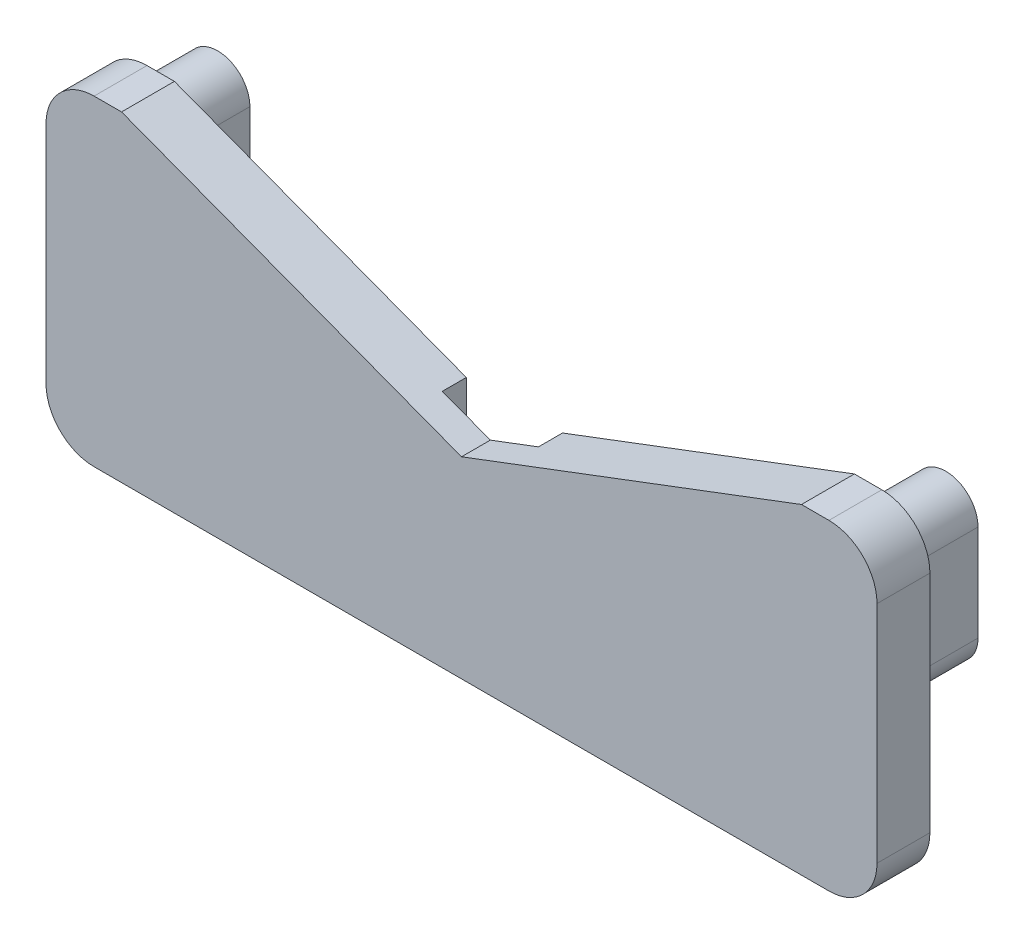
from build123d import *

# Parameters (mm, degrees)
BOSS_EXTRUDE1_DEPTH = 2.5
BOSS_EXTRUDE3_START = 2.5
BOSS_EXTRUDE3_DEPTH = 3
BOSS_EXTRUDE2_DEPTH = 7


with BuildPart() as part:
    # Sketch1 → Boss-Extrude1 (new body)
    with BuildSketch(Plane.XY):
        with BuildLine():
            ThreePointArc((-43.2, -11.688179282), (-41.735533906, -15.223713187), (-38.2, -16.688179282))
            Line((-38.2, -16.688179282), (-5, -16.688179282))
            Line((-5, -16.688179282), (-5, 5.203986913))
            Line((-5, 5.203986913), (-35.346679904, 16.688179282))
            Line((-35.346679904, 16.688179282), (-38.2, 16.688179282))
            ThreePointArc((-38.2, 16.688179282), (-41.735533906, 15.223713187), (-43.2, 11.688179282))
            Line((-43.2, 11.688179282), (-43.2, -11.688179282))
        make_face()
        with BuildLine():
            ThreePointArc((-41.2, 11.338179282), (-37.85, 14.688179282), (-34.5, 11.338179282))
            Line((-34.5, 11.338179282), (-34.5, 1.338179282))
            ThreePointArc((-34.5, 1.338179282), (-37.85, -2.011820718), (-41.2, 1.338179282))
            Line((-41.2, 1.338179282), (-41.2, 11.338179282))
        make_face(mode=Mode.SUBTRACT)
        with BuildLine():
            Line((-41.2, 11.338179282), (-41.2, 1.338179282))
            ThreePointArc((-41.2, 1.338179282), (-37.85, -2.011820718), (-34.5, 1.338179282))
            Line((-34.5, 1.338179282), (-34.5, 11.338179282))
            ThreePointArc((-34.5, 11.338179282), (-37.85, 14.688179282), (-41.2, 11.338179282))
        make_face()
        with BuildLine():
            Line((5, 5.203986913), (5, -16.688179282))
            Line((5, -16.688179282), (38.2, -16.688179282))
            ThreePointArc((38.2, -16.688179282), (41.735533906, -15.223713187), (43.2, -11.688179282))
            Line((43.2, -11.688179282), (43.2, 11.688179282))
            ThreePointArc((43.2, 11.688179282), (41.735533906, 15.223713187), (38.2, 16.688179282))
            Line((38.2, 16.688179282), (35.346679904, 16.688179282))
            Line((35.346679904, 16.688179282), (5, 5.203986913))
        make_face()
        with BuildLine():
            ThreePointArc((34.5, 11.338179282), (37.85, 14.688179282), (41.2, 11.338179282))
            Line((41.2, 11.338179282), (41.2, 1.338179282))
            ThreePointArc((41.2, 1.338179282), (37.85, -2.011820718), (34.5, 1.338179282))
            Line((34.5, 1.338179282), (34.5, 11.338179282))
        make_face(mode=Mode.SUBTRACT)
        with BuildLine():
            Line((34.5, 11.338179282), (34.5, 1.338179282))
            ThreePointArc((34.5, 1.338179282), (37.85, -2.011820718), (41.2, 1.338179282))
            Line((41.2, 1.338179282), (41.2, 11.338179282))
            ThreePointArc((41.2, 11.338179282), (37.85, 14.688179282), (34.5, 11.338179282))
        make_face()
    extrude(amount=BOSS_EXTRUDE1_DEPTH)

    # Sketch1_4 → Boss-Extrude3 (add)
    with BuildSketch(Plane.XY.offset(BOSS_EXTRUDE3_START)):
        with BuildLine():
            ThreePointArc((-43.2, -11.688179282), (-41.735533906, -15.223713187), (-38.2, -16.688179282))
            Line((-38.2, -16.688179282), (-5, -16.688179282))
            Line((-5, -16.688179282), (-5, 5.203986913))
            Line((-5, 5.203986913), (-35.346679904, 16.688179282))
            Line((-35.346679904, 16.688179282), (-38.2, 16.688179282))
            ThreePointArc((-38.2, 16.688179282), (-41.735533906, 15.223713187), (-43.2, 11.688179282))
            Line((-43.2, 11.688179282), (-43.2, -11.688179282))
        make_face()
        with BuildLine():
            ThreePointArc((-41.2, 11.338179282), (-37.85, 14.688179282), (-34.5, 11.338179282))
            Line((-34.5, 11.338179282), (-34.5, 1.338179282))
            ThreePointArc((-34.5, 1.338179282), (-37.85, -2.011820718), (-41.2, 1.338179282))
            Line((-41.2, 1.338179282), (-41.2, 11.338179282))
        make_face(mode=Mode.SUBTRACT)
        Polygon((-5, 5.203986913), (-5, -16.688179282), (5, -16.688179282), (5, 5.203986913), (0, 3.311820718), align=None)
        with BuildLine():
            Line((5, 5.203986913), (5, -16.688179282))
            Line((5, -16.688179282), (38.2, -16.688179282))
            ThreePointArc((38.2, -16.688179282), (41.735533906, -15.223713187), (43.2, -11.688179282))
            Line((43.2, -11.688179282), (43.2, 11.688179282))
            ThreePointArc((43.2, 11.688179282), (41.735533906, 15.223713187), (38.2, 16.688179282))
            Line((38.2, 16.688179282), (35.346679904, 16.688179282))
            Line((35.346679904, 16.688179282), (5, 5.203986913))
        make_face()
        with BuildLine():
            ThreePointArc((34.5, 11.338179282), (37.85, 14.688179282), (41.2, 11.338179282))
            Line((41.2, 11.338179282), (41.2, 1.338179282))
            ThreePointArc((41.2, 1.338179282), (37.85, -2.011820718), (34.5, 1.338179282))
            Line((34.5, 1.338179282), (34.5, 11.338179282))
        make_face(mode=Mode.SUBTRACT)
        with BuildLine():
            Line((34.5, 11.338179282), (34.5, 1.338179282))
            ThreePointArc((34.5, 1.338179282), (37.85, -2.011820718), (41.2, 1.338179282))
            Line((41.2, 1.338179282), (41.2, 11.338179282))
            ThreePointArc((41.2, 11.338179282), (37.85, 14.688179282), (34.5, 11.338179282))
        make_face()
        with BuildLine():
            Line((-41.2, 11.338179282), (-41.2, 1.338179282))
            ThreePointArc((-41.2, 1.338179282), (-37.85, -2.011820718), (-34.5, 1.338179282))
            Line((-34.5, 1.338179282), (-34.5, 11.338179282))
            ThreePointArc((-34.5, 11.338179282), (-37.85, 14.688179282), (-41.2, 11.338179282))
        make_face()
    extrude(amount=BOSS_EXTRUDE3_DEPTH)

    # Sketch1_3 → Boss-Extrude2 (add)
    with BuildSketch(Plane.XY):
        with BuildLine():
            Line((34.5, 11.338179282), (34.5, 1.338179282))
            ThreePointArc((34.5, 1.338179282), (37.85, -2.011820718), (41.2, 1.338179282))
            Line((41.2, 1.338179282), (41.2, 11.338179282))
            ThreePointArc((41.2, 11.338179282), (37.85, 14.688179282), (34.5, 11.338179282))
        make_face()
        with BuildLine():
            Line((-41.2, 11.338179282), (-41.2, 1.338179282))
            ThreePointArc((-41.2, 1.338179282), (-37.85, -2.011820718), (-34.5, 1.338179282))
            Line((-34.5, 1.338179282), (-34.5, 11.338179282))
            ThreePointArc((-34.5, 11.338179282), (-37.85, 14.688179282), (-41.2, 11.338179282))
        make_face()
    extrude(amount=-BOSS_EXTRUDE2_DEPTH)


solid = part.part
